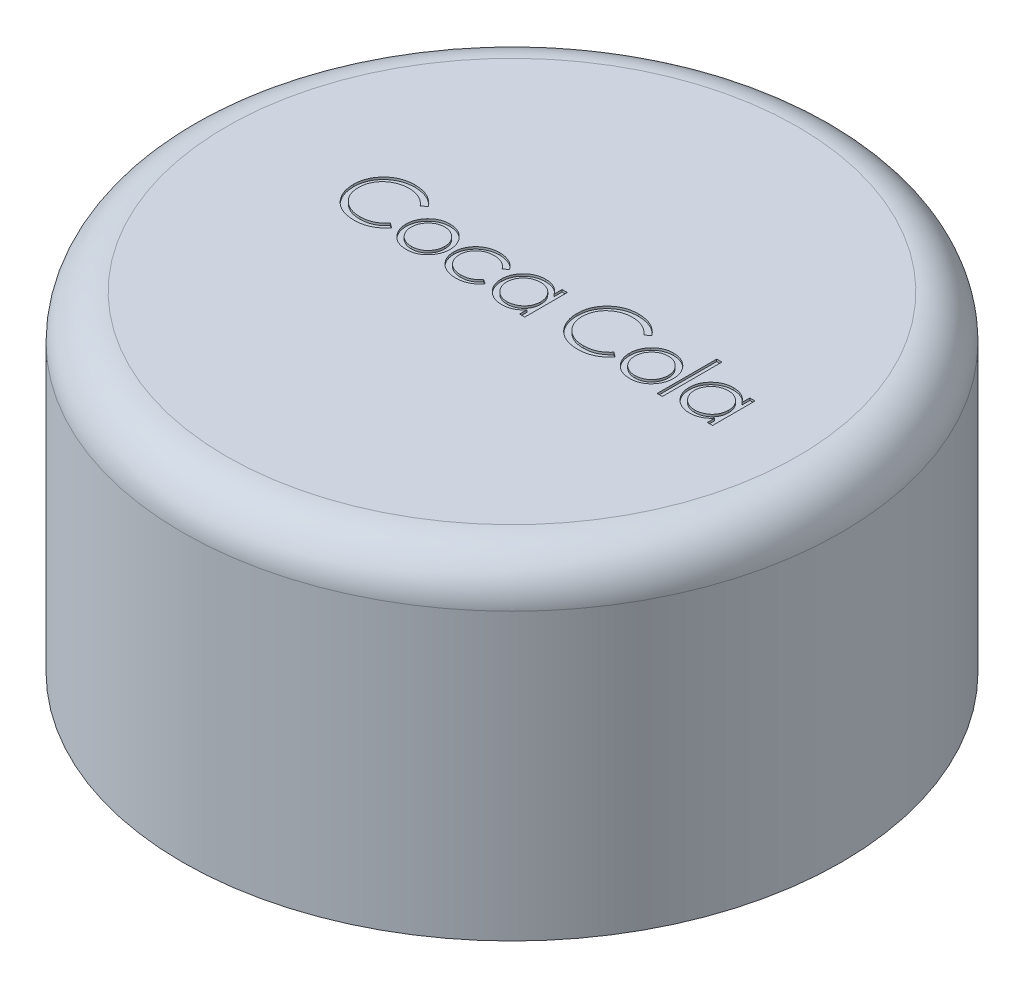
from build123d import *

# Parameters (mm, degrees)
CROQUIS1_R              = 15
CROQUIS1_R_2            = 13.85
SALIENTE_EXTRUIR1_DEPTH = 7.5
CROQUIS2_R              = 15
SALIENTE_EXTRUIR2_DEPTH = 2.15
REDONDEO1_R             = 2
CROQUIS3_W              = 0.237446581
CROQUIS3_H              = 2.713675213
CORTAR_EXTRUIR1_DEPTH   = 0.1


with BuildPart() as part:
    # Croquis1 → Saliente-Extruir1 (new body, symmetric)
    with BuildSketch(Plane(origin=(0, 0, 0), x_dir=(1, 0, 0), z_dir=(0, 1, 0))):
        Circle(CROQUIS1_R)
        Circle(CROQUIS1_R_2, mode=Mode.SUBTRACT)
    extrude(amount=SALIENTE_EXTRUIR1_DEPTH, both=True)

    # Croquis2 → Saliente-Extruir2 (add)
    with BuildSketch(Plane(origin=(0, 7.5, 0), x_dir=(1, 0, 0), z_dir=(0, 1, 0))):
        Circle(CROQUIS2_R)
    extrude(amount=-SALIENTE_EXTRUIR2_DEPTH)

    # Redondeo1
    redondeo1_edges = [part.edges().sort_by_distance(p)[0] for p in [
        (-15, 7.5, 0),
    ]]
    fillet(redondeo1_edges, radius=REDONDEO1_R)

    # Croquis3 → Cortar-Extruir1 (cut)
    with BuildSketch(Plane(origin=(0, 7.5, 0), x_dir=(1, 0, 0), z_dir=(0, 1, 0))):
        with BuildLine():
            Line((-5.255127494, 1.443894817), (-5.462893253, 1.28489041))
            add(Edge.make_bspline(
                [(-5.462893253, 1.28489041), (-5.477714371, 1.30255397), (-5.507156786, 1.337642948), (-5.554524159, 1.38691558), (-5.603889092, 1.43307801), (-5.655232713, 1.476350145), (-5.709479191, 1.515218772), (-5.765314437, 1.551709427), (-5.823672483, 1.584417776), (-5.904371711, 1.624077296), (-6.009938835, 1.665462782), (-6.142831362, 1.700163439), (-6.281557014, 1.722253256), (-6.376200437, 1.724645726), (-6.424339901, 1.725862632)],
                knots=[0, 0, 0, 0, 6.9158e-05, 0.000137384, 0.000204881, 0.000271861, 0.000338651, 0.000404954, 0.000471878, 0.000539197, 0.000674629, 0.00081116, 0.000950585, 0.001094913, 0.001094913, 0.001094913, 0.001094913], degree=3))
            add(Edge.make_bspline(
                [(-6.424339901, 1.725862632), (-6.450861205, 1.725557256), (-6.503657669, 1.724949337), (-6.58201098, 1.716929344), (-6.658901203, 1.705657179), (-6.734278323, 1.688931488), (-6.808046393, 1.66778552), (-6.880687673, 1.642517499), (-6.951150448, 1.611255209), (-7.020409473, 1.576701941), (-7.086766377, 1.537674051), (-7.149552038, 1.495103839), (-7.208537466, 1.449467677), (-7.263769322, 1.400594519), (-7.315304068, 1.348704466), (-7.362768285, 1.293244517), (-7.405997732, 1.234391981), (-7.445849293, 1.172922917), (-7.481539871, 1.109016372), (-7.511422578, 1.042435813), (-7.537884783, 0.974321402), (-7.558824092, 0.90390356), (-7.575397982, 0.831677778), (-7.586833775, 0.757450219), (-7.59476256, 0.681375949), (-7.595367456, 0.629812957), (-7.595672366, 0.603821533)],
                knots=[0, 0, 0, 0, 7.953e-05, 0.000158323, 0.000236054, 0.000312571, 0.000389743, 0.000466183, 0.000543086, 0.000620832, 0.000698279, 0.00077384, 0.000848263, 0.000921857, 0.000994939, 0.001067489, 0.001140633, 0.001213846, 0.001287153, 0.001359968, 0.001432611, 0.001506222, 0.001580153, 0.001654742, 0.001731424, 0.001809365, 0.001809365, 0.001809365, 0.001809365], degree=3))
            add(Edge.make_bspline(
                [(-7.595672366, 0.603821533), (-7.594718491, 0.564715119), (-7.592845684, 0.487934861), (-7.576178193, 0.375471364), (-7.55084994, 0.267732521), (-7.512889355, 0.165391807), (-7.466081501, 0.067187274), (-7.406935325, -0.025219478), (-7.338433537, -0.113224857), (-7.259607042, -0.19474899), (-7.173121693, -0.269220675), (-7.080330117, -0.334799984), (-6.981463423, -0.389466592), (-6.877613232, -0.434956742), (-6.767980396, -0.469924625), (-6.652762063, -0.494541552), (-6.532208829, -0.510599629), (-6.449833152, -0.512137), (-6.407909446, -0.512919419)],
                knots=[0, 0, 0, 0, 0.000117253, 0.000230211, 0.000340379, 0.000448694, 0.000557026, 0.000666132, 0.000777139, 0.000891093, 0.001005725, 0.001119096, 0.001231322, 0.001344067, 0.001458716, 0.001575878, 0.00169717, 0.001822874, 0.001822874, 0.001822874, 0.001822874], degree=3))
            add(Edge.make_bspline(
                [(-6.407909446, -0.512919419), (-6.361718722, -0.511642782), (-6.270804329, -0.509130055), (-6.1374785, -0.487843004), (-6.009846701, -0.453327792), (-5.887902067, -0.405024005), (-5.771988376, -0.342230603), (-5.661924234, -0.266107803), (-5.557616737, -0.175931504), (-5.494894399, -0.107076996), (-5.462893253, -0.071947197)],
                knots=[0, 0, 0, 0, 0.000138505, 0.000272612, 0.000403886, 0.000534492, 0.000665157, 0.000798504, 0.00093527, 0.001077735, 0.001077735, 0.001077735, 0.001077735], degree=3))
            Line((-5.462893253, -0.071947197), (-5.255127494, -0.22936156))
            add(Edge.make_bspline(
                [(-5.255127494, -0.22936156), (-5.271847732, -0.250935271), (-5.305208119, -0.293979355), (-5.359226977, -0.354660945), (-5.416133029, -0.411738401), (-5.476348953, -0.464751543), (-5.539182045, -0.514761169), (-5.60576052, -0.560346482), (-5.675209133, -0.602143757), (-5.747292579, -0.640415301), (-5.821934268, -0.674370601), (-5.899044764, -0.703439818), (-5.978291687, -0.728480658), (-6.05967866, -0.749081824), (-6.1433745, -0.765161751), (-6.22907718, -0.775911148), (-6.316971669, -0.783275571), (-6.376269648, -0.783946793), (-6.406319402, -0.784286941)],
                knots=[0, 0, 0, 0, 8.1865e-05, 0.000163337, 0.000243539, 0.000323515, 0.000403891, 0.000484308, 0.000565388, 0.000646949, 0.000729019, 0.000811214, 0.000894022, 0.000978221, 0.001062938, 0.001149519, 0.001237243, 0.00132737, 0.00132737, 0.00132737, 0.00132737], degree=3))
            add(Edge.make_bspline(
                [(-6.406319402, -0.784286941), (-6.434776221, -0.784088887), (-6.491046058, -0.78369726), (-6.574124281, -0.777353181), (-6.65500331, -0.768697725), (-6.733451985, -0.755665007), (-6.809898407, -0.740285654), (-6.883649563, -0.719669883), (-6.95543118, -0.696576168), (-7.024954866, -0.669433708), (-7.092279759, -0.638805403), (-7.157188711, -0.604189165), (-7.219651871, -0.565876089), (-7.28028335, -0.524710694), (-7.338187476, -0.47937071), (-7.393866034, -0.430485813), (-7.447631239, -0.37822077), (-7.480895174, -0.340532874), (-7.497619649, -0.321584116)],
                knots=[0, 0, 0, 0, 8.5347e-05, 0.000168763, 0.000249828, 0.000329295, 0.000407256, 0.000483631, 0.000558888, 0.000633396, 0.000707395, 0.000780662, 0.000853927, 0.000927138, 0.001000399, 0.00107439, 0.001149349, 0.001225147, 0.001225147, 0.001225147, 0.001225147], degree=3))
            add(Edge.make_bspline(
                [(-7.497619649, -0.321584116), (-7.524407308, -0.288669051), (-7.577659222, -0.223236299), (-7.645789947, -0.117186778), (-7.704109825, -0.006463787), (-7.751263051, 0.109514374), (-7.788125355, 0.230487458), (-7.81366233, 0.356516448), (-7.830256697, 0.487483643), (-7.832154356, 0.576562644), (-7.833118947, 0.621842032)],
                knots=[0, 0, 0, 0, 0.000127231, 0.000252926, 0.000377389, 0.000502191, 0.000627939, 0.00075621, 0.000887559, 0.001023346, 0.001023346, 0.001023346, 0.001023346], degree=3))
            add(Edge.make_bspline(
                [(-7.833118947, 0.621842032), (-7.831943295, 0.669433357), (-7.829630273, 0.763066318), (-7.809978689, 0.900478771), (-7.778365671, 1.032128936), (-7.733464451, 1.157771052), (-7.676537192, 1.278065966), (-7.606213502, 1.392094734), (-7.523310364, 1.500586601), (-7.428477977, 1.601895371), (-7.324483622, 1.694529286), (-7.213117614, 1.776025643), (-7.094597928, 1.843847813), (-6.970230266, 1.90054134), (-6.839083352, 1.944117809), (-6.701436996, 1.974622897), (-6.55754984, 1.993610241), (-6.45938003, 1.996010547), (-6.40949949, 1.997230153)],
                knots=[0, 0, 0, 0, 0.000142716, 0.000280784, 0.000415505, 0.000548276, 0.000680327, 0.000814043, 0.000949414, 0.00108929, 0.001229699, 0.00136667, 0.00150249, 0.001638645, 0.001776082, 0.001916238, 0.002061065, 0.002210665, 0.002210665, 0.002210665, 0.002210665], degree=3))
            add(Edge.make_bspline(
                [(-6.40949949, 1.997230153), (-6.379099264, 1.99686568), (-6.318925078, 1.996144241), (-6.22990968, 1.989109241), (-6.14324554, 1.977381693), (-6.058872953, 1.96141895), (-5.976381451, 1.941607463), (-5.896401507, 1.915799023), (-5.818463809, 1.886289265), (-5.743059897, 1.852302805), (-5.670551552, 1.814152352), (-5.600961359, 1.772260779), (-5.534842091, 1.726680022), (-5.471728497, 1.67779774), (-5.412676361, 1.624579782), (-5.356009053, 1.568489932), (-5.303650976, 1.507912577), (-5.271331597, 1.465273133), (-5.255127494, 1.443894817)],
                knots=[0, 0, 0, 0, 9.1187e-05, 0.000180496, 0.000267672, 0.000353431, 0.000438016, 0.000521994, 0.000605369, 0.000687922, 0.000769951, 0.000851031, 0.000931448, 0.001010752, 0.001090332, 0.001169785, 0.00124981, 0.001330276, 0.001330276, 0.001330276, 0.001330276], degree=3))
        make_face()
        with BuildLine():
            add(Edge.make_bspline(
                [(-4.070226653, 1.25096947), (-4.033947536, 1.250196969), (-3.962813054, 1.248682283), (-3.858636855, 1.232493589), (-3.759194996, 1.207738141), (-3.664106624, 1.173514995), (-3.574589544, 1.12764233), (-3.489339853, 1.072904354), (-3.408591281, 1.008056799), (-3.36019292, 0.957893259), (-3.335626293, 0.932430641)],
                knots=[0, 0, 0, 0, 0.000108758, 0.000213247, 0.000315443, 0.000415879, 0.000515669, 0.000616524, 0.000719414, 0.000825476, 0.000825476, 0.000825476, 0.000825476], degree=3))
            add(Edge.make_bspline(
                [(-3.335626293, 0.932430641), (-3.314473268, 0.908078402), (-3.272576587, 0.859845206), (-3.218854288, 0.781637689), (-3.172573704, 0.700644875), (-3.135484442, 0.615791241), (-3.106240406, 0.527817531), (-3.085477648, 0.436421368), (-3.073127703, 0.341804594), (-3.071462365, 0.27754574), (-3.070618947, 0.245001588)],
                knots=[0, 0, 0, 0, 9.6703e-05, 0.000191534, 0.000284097, 0.000376175, 0.000468861, 0.00056182, 0.000656947, 0.000754562, 0.000754562, 0.000754562, 0.000754562], degree=3))
            add(Edge.make_bspline(
                [(-3.070618947, 0.245001588), (-3.071360792, 0.212268806), (-3.072826711, 0.147587303), (-3.086693611, 0.052322663), (-3.108261753, -0.040050804), (-3.139128679, -0.129146364), (-3.178708916, -0.215236359), (-3.227007233, -0.297944768), (-3.284362563, -0.377434773), (-3.349377489, -0.453031401), (-3.421232181, -0.522704671), (-3.499183079, -0.583429017), (-3.581698331, -0.635454812), (-3.669875151, -0.677362103), (-3.762908311, -0.710404555), (-3.860998476, -0.733612305), (-3.963993261, -0.747644054), (-4.034317411, -0.749445922), (-4.070226653, -0.750366)],
                knots=[0, 0, 0, 0, 9.8144e-05, 0.000193938, 0.00028817, 0.00038237, 0.000476284, 0.000572006, 0.000669231, 0.000769951, 0.000870783, 0.00096896, 0.001065874, 0.001162833, 0.001261235, 0.001361507, 0.001464724, 0.001572422, 0.001572422, 0.001572422, 0.001572422], degree=3))
            add(Edge.make_bspline(
                [(-4.070226653, -0.750366), (-4.106311828, -0.749442834), (-4.176986466, -0.747634767), (-4.280344798, -0.733666821), (-4.37861076, -0.710415251), (-4.471765712, -0.677253515), (-4.560321638, -0.635453473), (-4.643315002, -0.583586303), (-4.721329224, -0.522686662), (-4.793199117, -0.453036281), (-4.858209967, -0.377433516), (-4.915566348, -0.297945094), (-4.963864392, -0.215236274), (-5.003444701, -0.129146387), (-5.034311608, -0.040050798), (-5.055879755, 0.052322662), (-5.069746654, 0.147587303), (-5.071212573, 0.212268806), (-5.071954418, 0.245001588)],
                knots=[0, 0, 0, 0, 0.000108228, 0.00021197, 0.000312243, 0.000410644, 0.000508082, 0.000605445, 0.000703622, 0.000804454, 0.000905174, 0.001002399, 0.001098121, 0.001192035, 0.001286235, 0.001380467, 0.001476261, 0.001574405, 0.001574405, 0.001574405, 0.001574405], degree=3))
            add(Edge.make_bspline(
                [(-5.071954418, 0.245001588), (-5.071105248, 0.277368858), (-5.069424039, 0.341450489), (-5.057086512, 0.435889398), (-5.036404746, 0.527130877), (-5.007125654, 0.614765016), (-4.969694528, 0.699246804), (-4.924064269, 0.780439742), (-4.869793969, 0.858293615), (-4.828063922, 0.906464473), (-4.806947072, 0.930840597)],
                knots=[0, 0, 0, 0, 9.7085e-05, 0.000192212, 0.000285172, 0.000377355, 0.000468948, 0.000561973, 0.000656369, 0.000753072, 0.000753072, 0.000753072, 0.000753072], degree=3))
            add(Edge.make_bspline(
                [(-4.806947072, 0.930840597), (-4.782417483, 0.956524033), (-4.734175729, 1.00703503), (-4.653025202, 1.071693545), (-4.56798523, 1.127570577), (-4.477478887, 1.172531764), (-4.382468632, 1.207939453), (-4.28251718, 1.232557431), (-4.177987475, 1.248623956), (-4.106504905, 1.25017984), (-4.070226653, 1.25096947)],
                knots=[0, 0, 0, 0, 0.000106437, 0.000209326, 0.000310469, 0.000411207, 0.000511826, 0.000614021, 0.000719559, 0.000828317, 0.000828317, 0.000828317, 0.000828317], degree=3))
        make_face()
        with BuildLine():
            add(Edge.make_bspline(
                [(-4.071286683, 1.013522889), (-4.096941901, 1.012793703), (-4.147590051, 1.011354156), (-4.222141761, 1.000405014), (-4.293911997, 0.983057794), (-4.363036921, 0.95841068), (-4.429283426, 0.926585917), (-4.492714938, 0.887496859), (-4.553518033, 0.841661231), (-4.610503283, 0.789150759), (-4.662801817, 0.731789852), (-4.708520287, 0.670672343), (-4.747395219, 0.606789569), (-4.779780339, 0.5400751), (-4.803900654, 0.469852859), (-4.821418355, 0.396918096), (-4.832357168, 0.321122215), (-4.83378318, 0.269595731), (-4.834507836, 0.243411544)],
                knots=[0, 0, 0, 0, 7.6942e-05, 0.000151897, 0.000225556, 0.000298145, 0.000371633, 0.000445627, 0.000521313, 0.000599714, 0.000677758, 0.000753868, 0.000828314, 0.000901803, 0.000975891, 0.00105058, 0.001126585, 0.001205115, 0.001205115, 0.001205115, 0.001205115], degree=3))
            add(Edge.make_bspline(
                [(-4.834507836, 0.243411544), (-4.833293154, 0.209581142), (-4.830882237, 0.142434121), (-4.811276434, 0.043547142), (-4.778478472, -0.051386758), (-4.734189278, -0.14181105), (-4.678697673, -0.225474022), (-4.613317569, -0.300064966), (-4.538750652, -0.364461383), (-4.455885798, -0.417892736), (-4.36641557, -0.460346837), (-4.271727755, -0.490432968), (-4.172969612, -0.509990735), (-4.10547763, -0.511934647), (-4.071286683, -0.512919419)],
                knots=[0, 0, 0, 0, 0.000101432, 0.000201324, 0.000301053, 0.00040203, 0.000502578, 0.00060135, 0.000698678, 0.000797177, 0.000896278, 0.000994835, 0.001094627, 0.001197086, 0.001197086, 0.001197086, 0.001197086], degree=3))
            add(Edge.make_bspline(
                [(-4.071286683, -0.512919419), (-4.037097701, -0.51192891), (-3.969609602, -0.509973671), (-3.870988677, -0.490531468), (-3.776559662, -0.460215011), (-3.687182363, -0.417940483), (-3.604355228, -0.364258479), (-3.529252024, -0.300428599), (-3.464430157, -0.225276461), (-3.408993444, -0.141700234), (-3.363978942, -0.051526944), (-3.331334498, 0.043564663), (-3.311681561, 0.142429659), (-3.309277006, 0.209579647), (-3.308065529, 0.243411544)],
                knots=[0, 0, 0, 0, 0.000102459, 0.000202251, 0.000300304, 0.000399405, 0.000497904, 0.000595634, 0.000694057, 0.000794604, 0.000895816, 0.000995545, 0.001095437, 0.001196869, 0.001196869, 0.001196869, 0.001196869], degree=3))
            add(Edge.make_bspline(
                [(-3.308065529, 0.243411544), (-3.308789935, 0.269595888), (-3.310215457, 0.32112268), (-3.32115784, 0.39691632), (-3.338662326, 0.469859373), (-3.362831346, 0.540051066), (-3.395075749, 0.606962304), (-3.434700349, 0.670484776), (-3.480232136, 0.73200157), (-3.533161745, 0.788965334), (-3.590087513, 0.841681701), (-3.65091525, 0.887514632), (-3.714252704, 0.926414124), (-3.780306752, 0.958682889), (-3.849440538, 0.982833557), (-3.921110213, 1.000505178), (-3.995343837, 1.011307886), (-4.045810495, 1.012779832), (-4.071286683, 1.013522889)],
                knots=[0, 0, 0, 0, 7.853e-05, 0.000154535, 0.000229224, 0.000303312, 0.000376801, 0.000451523, 0.000527634, 0.000606035, 0.000684436, 0.000760122, 0.000834116, 0.000907127, 0.000980215, 0.001053359, 0.001128314, 0.001204727, 0.001204727, 0.001204727, 0.001204727], degree=3))
        make_face(mode=Mode.SUBTRACT)
        with BuildLine():
            Line((-0.920031341, 0.79780691), (-1.118786849, 0.674313487))
            add(Edge.make_bspline(
                [(-1.118786849, 0.674313487), (-1.140580855, 0.701398046), (-1.183478654, 0.754709404), (-1.257969625, 0.823508579), (-1.337353253, 0.882599141), (-1.422986063, 0.930756143), (-1.514747948, 0.967965216), (-1.612277032, 0.994295192), (-1.715559407, 1.010702566), (-1.786365838, 1.012567378), (-1.822646358, 1.013522889)],
                knots=[0, 0, 0, 0, 0.00010417, 0.000205042, 0.000303203, 0.000400501, 0.000498924, 0.000599472, 0.000702993, 0.000811776, 0.000811776, 0.000811776, 0.000811776], degree=3))
            add(Edge.make_bspline(
                [(-1.822646358, 1.013522889), (-1.851643903, 1.012723966), (-1.908753779, 1.01115051), (-1.99259355, 1.001315197), (-2.072454138, 0.983442964), (-2.148836102, 0.959894324), (-2.221196181, 0.928333093), (-2.289723958, 0.889923337), (-2.355027275, 0.845284319), (-2.41521374, 0.793569204), (-2.470269002, 0.737327354), (-2.517968776, 0.677037358), (-2.559498481, 0.614505059), (-2.592084532, 0.548168921), (-2.618750881, 0.479546547), (-2.636294056, 0.407342621), (-2.64798463, 0.332482163), (-2.649322158, 0.281441513), (-2.649999289, 0.255601882)],
                knots=[0, 0, 0, 0, 8.7002e-05, 0.000171347, 0.000252751, 0.000332207, 0.00041078, 0.00048908, 0.000567587, 0.000647668, 0.000726754, 0.000803321, 0.000878, 0.000951479, 0.001024617, 0.001098404, 0.00117396, 0.001251431, 0.001251431, 0.001251431, 0.001251431], degree=3))
            add(Edge.make_bspline(
                [(-2.649999289, 0.255601882), (-2.648654259, 0.22175849), (-2.645982323, 0.154527717), (-2.625041338, 0.055287723), (-2.590763126, -0.040660543), (-2.543850346, -0.132635861), (-2.484525369, -0.21775168), (-2.4148473, -0.294090363), (-2.334777517, -0.360172718), (-2.245021529, -0.414958496), (-2.147686806, -0.459001315), (-2.043826429, -0.490378882), (-1.934289095, -0.509317283), (-1.859293519, -0.511703026), (-1.821056314, -0.512919419)],
                knots=[0, 0, 0, 0, 0.000101467, 0.000201567, 0.00030282, 0.000406407, 0.000510356, 0.000613143, 0.000715547, 0.000820721, 0.000927707, 0.00103518, 0.001145405, 0.001260065, 0.001260065, 0.001260065, 0.001260065], degree=3))
            add(Edge.make_bspline(
                [(-1.821056314, -0.512919419), (-1.786014002, -0.511937061), (-1.71714656, -0.510006467), (-1.616478434, -0.493731596), (-1.520638858, -0.467089087), (-1.42963124, -0.429935804), (-1.343621876, -0.381912027), (-1.263166488, -0.322676225), (-1.186664154, -0.253932486), (-1.141687273, -0.200775448), (-1.118786849, -0.173710017)],
                knots=[0, 0, 0, 0, 0.000105077, 0.000206504, 0.000305008, 0.00040294, 0.0005007, 0.000599717, 0.000702147, 0.0008084, 0.0008084, 0.0008084, 0.0008084], degree=3))
            Line((-1.118786849, -0.173710017), (-0.920031341, -0.304093631))
            add(Edge.make_bspline(
                [(-0.920031341, -0.304093631), (-0.931814901, -0.321397931), (-0.955342911, -0.355949095), (-0.994673319, -0.404665778), (-1.037097239, -0.450266097), (-1.082449163, -0.492688928), (-1.130136915, -0.532949455), (-1.181789561, -0.569122966), (-1.235741589, -0.603242743), (-1.292626369, -0.63394414), (-1.351855765, -0.661541181), (-1.413346436, -0.685271411), (-1.476831175, -0.705659527), (-1.542384626, -0.72186514), (-1.610136026, -0.734800119), (-1.679910154, -0.743382977), (-1.751682981, -0.749789886), (-1.800194071, -0.750172297), (-1.824766417, -0.750366)],
                knots=[0, 0, 0, 0, 6.2786e-05, 0.000125364, 0.000187617, 0.000249484, 0.000311577, 0.000374669, 0.000438491, 0.000502998, 0.000568446, 0.000634392, 0.000700601, 0.000768346, 0.000836849, 0.000907389, 0.000979178, 0.001052867, 0.001052867, 0.001052867, 0.001052867], degree=3))
            add(Edge.make_bspline(
                [(-1.824766417, -0.750366), (-1.862269882, -0.749692235), (-1.935776947, -0.748371651), (-2.043365986, -0.733850958), (-2.146185841, -0.711960379), (-2.244201386, -0.680540176), (-2.337427878, -0.640093113), (-2.42577839, -0.590686398), (-2.50896038, -0.531909747), (-2.58615127, -0.464809321), (-2.657045577, -0.392055979), (-2.717919542, -0.313550386), (-2.770719241, -0.23217888), (-2.813118753, -0.146144298), (-2.846869703, -0.056590117), (-2.869929904, 0.037201076), (-2.884844646, 0.134456054), (-2.886570772, 0.200777935), (-2.887445871, 0.234401294)],
                knots=[0, 0, 0, 0, 0.000112443, 0.000220389, 0.000325076, 0.00042749, 0.000528612, 0.000629461, 0.000730631, 0.000833593, 0.000935924, 0.001034846, 0.001131147, 0.001226433, 0.001322027, 0.001417666, 0.001515709, 0.001616524, 0.001616524, 0.001616524, 0.001616524], degree=3))
            add(Edge.make_bspline(
                [(-2.887445871, 0.234401294), (-2.887112483, 0.257214753), (-2.886449321, 0.30259449), (-2.878842983, 0.369946117), (-2.869016756, 0.436400792), (-2.852366348, 0.501116151), (-2.833134442, 0.565073721), (-2.808584486, 0.627502613), (-2.779786182, 0.688692932), (-2.747089769, 0.748487049), (-2.710283397, 0.805901284), (-2.66955175, 0.860143637), (-2.626428948, 0.911865722), (-2.578897602, 0.959281898), (-2.528974768, 1.004288424), (-2.475248041, 1.045682958), (-2.418025582, 1.08358716), (-2.358166761, 1.118701916), (-2.295706413, 1.149967679), (-2.231022085, 1.17690471), (-2.164503545, 1.199925407), (-2.096044389, 1.218150602), (-2.026099008, 1.233434011), (-1.954116211, 1.243048098), (-1.880371376, 1.249841292), (-1.830436168, 1.250590284), (-1.805155873, 1.25096947)],
                knots=[0, 0, 0, 0, 6.8405e-05, 0.000136068, 0.000203163, 0.000269751, 0.000336307, 0.000403433, 0.00047077, 0.000539084, 0.000607743, 0.000675162, 0.000742482, 0.000809568, 0.000876383, 0.00094402, 0.001012816, 0.001082175, 0.001152099, 0.001222183, 0.001292245, 0.001363089, 0.001434608, 0.001506865, 0.001580811, 0.001656633, 0.001656633, 0.001656633, 0.001656633], degree=3))
            add(Edge.make_bspline(
                [(-1.805155873, 1.25096947), (-1.773496506, 1.250272564), (-1.710336019, 1.248882236), (-1.616642747, 1.237181112), (-1.524329476, 1.219539892), (-1.435015891, 1.193404479), (-1.349784895, 1.161757549), (-1.27000512, 1.126218176), (-1.197554566, 1.084947255), (-1.131085495, 1.039801693), (-1.070473598, 0.988880056), (-1.01509669, 0.931573606), (-0.963819194, 0.868180589), (-0.934747751, 0.821458399), (-0.920031341, 0.79780691)],
                knots=[0, 0, 0, 0, 9.4945e-05, 0.000189416, 0.000282862, 0.000376633, 0.000468195, 0.000555485, 0.000638319, 0.000717999, 0.000796244, 0.00087533, 0.00095678, 0.00104028, 0.00104028, 0.00104028, 0.00104028], degree=3))
        make_face()
        with BuildLine():
            Line((1.298398147, 1.21704853), (1.298398147, -0.71644506))
            Line((1.298398147, -0.71644506), (1.060951565, -0.71644506))
            Line((1.060951565, -0.71644506), (1.060951565, -0.382005791))
            add(Edge.make_bspline(
                [(1.060951565, -0.382005791), (1.034176646, -0.412273817), (0.981925055, -0.471342251), (0.894657067, -0.548511513), (0.802152552, -0.612297506), (0.704860481, -0.663815597), (0.602868714, -0.702514354), (0.496403339, -0.730020557), (0.385420926, -0.747705183), (0.309634919, -0.749471104), (0.271229677, -0.750366)],
                knots=[0, 0, 0, 0, 0.000121151, 0.000236428, 0.000348455, 0.000457515, 0.000565889, 0.000674904, 0.000786968, 0.000902103, 0.000902103, 0.000902103, 0.000902103], degree=3))
            add(Edge.make_bspline(
                [(0.271229677, -0.750366), (0.237084855, -0.749438921), (0.169749753, -0.74761068), (0.070698011, -0.733427272), (-0.024621726, -0.710649957), (-0.116299528, -0.67897488), (-0.203742161, -0.636958426), (-0.287698306, -0.586656411), (-0.367733019, -0.526754116), (-0.442626385, -0.458273881), (-0.511593433, -0.383891956), (-0.572115943, -0.30455812), (-0.622578092, -0.220615426), (-0.664775415, -0.133126673), (-0.697278604, -0.04141837), (-0.719937244, 0.054192346), (-0.73410413, 0.153592429), (-0.735931615, 0.221280044), (-0.736858264, 0.255601882)],
                knots=[0, 0, 0, 0, 0.000102404, 0.000201945, 0.000299517, 0.000396067, 0.00049232, 0.000590034, 0.000689253, 0.000791683, 0.00089408, 0.000993194, 0.001090454, 0.001187414, 0.00128414, 0.001381711, 0.001481777, 0.001584711, 0.001584711, 0.001584711, 0.001584711], degree=3))
            add(Edge.make_bspline(
                [(-0.736858264, 0.255601882), (-0.735911077, 0.289214324), (-0.73403854, 0.35566431), (-0.720088785, 0.453392849), (-0.69663082, 0.547522725), (-0.663710721, 0.63775089), (-0.621496862, 0.724186524), (-0.570146463, 0.806890757), (-0.509655815, 0.886091432), (-0.439917388, 0.959926229), (-0.364371461, 1.028128717), (-0.283553551, 1.087402222), (-0.199474047, 1.138592935), (-0.110828795, 1.179152408), (-0.018929852, 1.211967624), (0.077040907, 1.234671117), (0.176684184, 1.24804945), (0.244334735, 1.249986777), (0.278649883, 1.25096947)],
                knots=[0, 0, 0, 0, 0.000100816, 0.000199307, 0.000295461, 0.000391368, 0.000486896, 0.000583529, 0.000682964, 0.000785334, 0.000887803, 0.000987873, 0.001085587, 0.001182574, 0.001279799, 0.001377887, 0.001477881, 0.001580814, 0.001580814, 0.001580814, 0.001580814], degree=3))
            add(Edge.make_bspline(
                [(0.278649883, 1.25096947), (0.31811049, 1.249882598), (0.39549088, 1.247751294), (0.508678125, 1.230014589), (0.615754605, 1.200049796), (0.717546883, 1.159290735), (0.813689426, 1.105127707), (0.903272039, 1.036804761), (0.987232255, 0.954752792), (1.03590069, 0.891728706), (1.060951565, 0.859288614)],
                knots=[0, 0, 0, 0, 0.000118337, 0.000232053, 0.000342644, 0.000451302, 0.000560235, 0.000672599, 0.000788411, 0.000911251, 0.000911251, 0.000911251, 0.000911251], degree=3))
            Line((1.060951565, 0.859288614), (1.060951565, 1.21704853))
            Line((1.060951565, 1.21704853), (1.298398147, 1.21704853))
        make_face()
        with BuildLine():
            add(Edge.make_bspline(
                [(0.281829971, 1.013522889), (0.247120918, 1.012287936), (0.178610768, 1.009850337), (0.078035838, 0.990820373), (-0.018207041, 0.959157614), (-0.109636514, 0.915855225), (-0.19480832, 0.86140493), (-0.27092794, 0.795545313), (-0.338617959, 0.720073284), (-0.39554742, 0.635329427), (-0.441955713, 0.544480513), (-0.474587933, 0.44951442), (-0.496109329, 0.35214399), (-0.498308032, 0.28610196), (-0.499411683, 0.252951808)],
                knots=[0, 0, 0, 0, 0.000104077, 0.000205432, 0.000305829, 0.0004073, 0.000508155, 0.000608127, 0.00070835, 0.0008114, 0.000913561, 0.001013462, 0.001112005, 0.001211322, 0.001211322, 0.001211322, 0.001211322], degree=3))
            add(Edge.make_bspline(
                [(-0.499411683, 0.252951808), (-0.498001912, 0.219999763), (-0.495187897, 0.154224833), (-0.474965646, 0.056721659), (-0.441038598, -0.038266813), (-0.394742515, -0.12993435), (-0.336771079, -0.215042569), (-0.26957549, -0.291953257), (-0.192505932, -0.358091219), (-0.107138114, -0.413455337), (-0.015964232, -0.458179386), (0.07991618, -0.489298649), (0.17870074, -0.509390186), (0.245868874, -0.511737022), (0.279709912, -0.512919419)],
                knots=[0, 0, 0, 0, 9.8823e-05, 0.000197259, 0.000297336, 0.000400683, 0.000504468, 0.000605484, 0.000706204, 0.00080808, 0.000910009, 0.001009903, 0.001109795, 0.001211227, 0.001211227, 0.001211227, 0.001211227], degree=3))
            add(Edge.make_bspline(
                [(0.279709912, -0.512919419), (0.314065304, -0.511664566), (0.382394771, -0.509168786), (0.48326808, -0.490057353), (0.581160106, -0.458482131), (0.674737356, -0.414713148), (0.76191086, -0.360468004), (0.840150327, -0.296962644), (0.906308231, -0.223103689), (0.962394311, -0.141932204), (1.006372156, -0.05294754), (1.038406439, 0.04179914), (1.057345998, 0.142311135), (1.059733092, 0.210999936), (1.060951565, 0.246061617)],
                knots=[0, 0, 0, 0, 0.000103019, 0.000204895, 0.000306804, 0.000410899, 0.000513992, 0.000614158, 0.000712096, 0.000810448, 0.000909289, 0.001008848, 0.001109681, 0.001214817, 0.001214817, 0.001214817, 0.001214817], degree=3))
            add(Edge.make_bspline(
                [(1.060951565, 0.246061617), (1.060226111, 0.272775334), (1.058798187, 0.325356383), (1.047889363, 0.402559923), (1.030536532, 0.476441966), (1.006084368, 0.547080189), (0.97396298, 0.61408404), (0.93522211, 0.677934621), (0.88918049, 0.738299846), (0.836579285, 0.794348477), (0.779002019, 0.845470863), (0.718076384, 0.891103354), (0.653080545, 0.928590105), (0.585107547, 0.959615352), (0.514039455, 0.984304114), (0.439297975, 1.000774573), (0.36167755, 1.012083863), (0.308726068, 1.013038163), (0.281829971, 1.013522889)],
                knots=[0, 0, 0, 0, 8.0118e-05, 0.000157698, 0.000233418, 0.000307506, 0.000381473, 0.000455919, 0.000531183, 0.000608806, 0.000686141, 0.000761935, 0.00083675, 0.000910749, 0.000985839, 0.001061955, 0.00114006, 0.001220685, 0.001220685, 0.001220685, 0.001220685], degree=3))
        make_face(mode=Mode.SUBTRACT)
        with BuildLine():
            Line((4.921154557, 1.443894817), (4.713388798, 1.28489041))
            add(Edge.make_bspline(
                [(4.713388798, 1.28489041), (4.69856768, 1.30255397), (4.669125265, 1.337642948), (4.621757892, 1.38691558), (4.572392959, 1.43307801), (4.521049338, 1.476350145), (4.466802861, 1.515218772), (4.410967614, 1.551709427), (4.352609568, 1.584417776), (4.27191034, 1.624077296), (4.166343217, 1.665462782), (4.03345069, 1.700163439), (3.894725038, 1.722253256), (3.800081614, 1.724645726), (3.75194215, 1.725862632)],
                knots=[0, 0, 0, 0, 6.9158e-05, 0.000137384, 0.000204881, 0.000271861, 0.000338651, 0.000404954, 0.000471878, 0.000539197, 0.000674629, 0.00081116, 0.000950585, 0.001094913, 0.001094913, 0.001094913, 0.001094913], degree=3))
            add(Edge.make_bspline(
                [(3.75194215, 1.725862632), (3.725420847, 1.725557256), (3.672624382, 1.724949337), (3.594271072, 1.716929344), (3.517380848, 1.705657179), (3.442003728, 1.688931488), (3.368235658, 1.66778552), (3.295594378, 1.642517499), (3.225131603, 1.611255209), (3.155872578, 1.576701941), (3.089515675, 1.537674051), (3.026730013, 1.495103839), (2.967744585, 1.449467677), (2.91251273, 1.400594519), (2.860977983, 1.348704466), (2.813513766, 1.293244517), (2.770284319, 1.234391981), (2.730432758, 1.172922917), (2.69474218, 1.109016372), (2.664859474, 1.042435813), (2.638397268, 0.974321402), (2.61745796, 0.90390356), (2.600884069, 0.831677778), (2.589448276, 0.757450219), (2.581519491, 0.681375949), (2.580914596, 0.629812957), (2.580609685, 0.603821533)],
                knots=[0, 0, 0, 0, 7.953e-05, 0.000158323, 0.000236054, 0.000312571, 0.000389743, 0.000466183, 0.000543086, 0.000620832, 0.000698279, 0.00077384, 0.000848263, 0.000921857, 0.000994939, 0.001067489, 0.001140633, 0.001213846, 0.001287153, 0.001359968, 0.001432611, 0.001506222, 0.001580153, 0.001654742, 0.001731424, 0.001809365, 0.001809365, 0.001809365, 0.001809365], degree=3))
            add(Edge.make_bspline(
                [(2.580609685, 0.603821533), (2.58156356, 0.564715119), (2.583436367, 0.487934861), (2.600103858, 0.375471364), (2.625432112, 0.267732521), (2.663392696, 0.165391807), (2.71020055, 0.067187274), (2.769346727, -0.025219478), (2.837848514, -0.113224857), (2.91667501, -0.19474899), (3.003160359, -0.269220675), (3.095951935, -0.334799984), (3.194818628, -0.389466592), (3.298668819, -0.434956742), (3.408301655, -0.469924625), (3.523519988, -0.494541552), (3.644073222, -0.510599629), (3.7264489, -0.512137), (3.768372606, -0.512919419)],
                knots=[0, 0, 0, 0, 0.000117253, 0.000230211, 0.000340379, 0.000448694, 0.000557026, 0.000666132, 0.000777139, 0.000891093, 0.001005725, 0.001119096, 0.001231322, 0.001344067, 0.001458716, 0.001575878, 0.00169717, 0.001822874, 0.001822874, 0.001822874, 0.001822874], degree=3))
            add(Edge.make_bspline(
                [(3.768372606, -0.512919419), (3.814563329, -0.511642782), (3.905477722, -0.509130055), (4.038803551, -0.487843004), (4.16643535, -0.453327792), (4.288379984, -0.405024005), (4.404293675, -0.342230603), (4.514357817, -0.266107803), (4.618665314, -0.175931504), (4.681387652, -0.107076996), (4.713388798, -0.071947197)],
                knots=[0, 0, 0, 0, 0.000138505, 0.000272612, 0.000403886, 0.000534492, 0.000665157, 0.000798504, 0.00093527, 0.001077735, 0.001077735, 0.001077735, 0.001077735], degree=3))
            Line((4.713388798, -0.071947197), (4.921154557, -0.22936156))
            add(Edge.make_bspline(
                [(4.921154557, -0.22936156), (4.904434319, -0.250935271), (4.871073932, -0.293979355), (4.817055074, -0.354660945), (4.760149022, -0.411738401), (4.699933098, -0.464751543), (4.637100006, -0.514761169), (4.570521532, -0.560346482), (4.501072918, -0.602143757), (4.428989473, -0.640415301), (4.354347783, -0.674370601), (4.277237288, -0.703439818), (4.197990364, -0.728480658), (4.116603391, -0.749081824), (4.032907551, -0.765161751), (3.947204871, -0.775911148), (3.859310382, -0.783275571), (3.800012403, -0.783946793), (3.76996265, -0.784286941)],
                knots=[0, 0, 0, 0, 8.1865e-05, 0.000163337, 0.000243539, 0.000323515, 0.000403891, 0.000484308, 0.000565388, 0.000646949, 0.000729019, 0.000811214, 0.000894022, 0.000978221, 0.001062938, 0.001149519, 0.001237243, 0.00132737, 0.00132737, 0.00132737, 0.00132737], degree=3))
            add(Edge.make_bspline(
                [(3.76996265, -0.784286941), (3.74150583, -0.784088887), (3.685235993, -0.78369726), (3.60215777, -0.777353181), (3.521278742, -0.768697725), (3.442830066, -0.755665007), (3.366383644, -0.740285654), (3.292632488, -0.719669883), (3.220850871, -0.696576168), (3.151327185, -0.669433708), (3.084002293, -0.638805403), (3.01909334, -0.604189165), (2.95663018, -0.565876089), (2.895998701, -0.524710694), (2.838094575, -0.47937071), (2.782416017, -0.430485813), (2.728650812, -0.37822077), (2.695386878, -0.340532874), (2.678662403, -0.321584116)],
                knots=[0, 0, 0, 0, 8.5347e-05, 0.000168763, 0.000249828, 0.000329295, 0.000407256, 0.000483631, 0.000558888, 0.000633396, 0.000707395, 0.000780662, 0.000853927, 0.000927138, 0.001000399, 0.00107439, 0.001149349, 0.001225147, 0.001225147, 0.001225147, 0.001225147], degree=3))
            add(Edge.make_bspline(
                [(2.678662403, -0.321584116), (2.651874744, -0.288669051), (2.59862283, -0.223236299), (2.530492105, -0.117186778), (2.472172226, -0.006463787), (2.425019001, 0.109514374), (2.388156696, 0.230487458), (2.362619722, 0.356516448), (2.346025354, 0.487483643), (2.344127695, 0.576562644), (2.343163104, 0.621842032)],
                knots=[0, 0, 0, 0, 0.000127231, 0.000252926, 0.000377389, 0.000502191, 0.000627939, 0.00075621, 0.000887559, 0.001023346, 0.001023346, 0.001023346, 0.001023346], degree=3))
            add(Edge.make_bspline(
                [(2.343163104, 0.621842032), (2.344338756, 0.669433357), (2.346651779, 0.763066318), (2.366303362, 0.900478771), (2.397916381, 1.032128936), (2.4428176, 1.157771052), (2.49974486, 1.278065966), (2.57006855, 1.392094734), (2.652971687, 1.500586601), (2.747804075, 1.601895371), (2.851798429, 1.694529286), (2.963164437, 1.776025643), (3.081684123, 1.843847813), (3.206051785, 1.90054134), (3.337198699, 1.944117809), (3.474845056, 1.974622897), (3.618732211, 1.993610241), (3.716902021, 1.996010547), (3.766782562, 1.997230153)],
                knots=[0, 0, 0, 0, 0.000142716, 0.000280784, 0.000415505, 0.000548276, 0.000680327, 0.000814043, 0.000949414, 0.00108929, 0.001229699, 0.00136667, 0.00150249, 0.001638645, 0.001776082, 0.001916238, 0.002061065, 0.002210665, 0.002210665, 0.002210665, 0.002210665], degree=3))
            add(Edge.make_bspline(
                [(3.766782562, 1.997230153), (3.797182787, 1.99686568), (3.857356973, 1.996144241), (3.946372371, 1.989109241), (4.033036511, 1.977381693), (4.117409098, 1.96141895), (4.1999006, 1.941607463), (4.279880544, 1.915799023), (4.357818242, 1.886289265), (4.433222155, 1.852302805), (4.505730499, 1.814152352), (4.575320692, 1.772260779), (4.64143996, 1.726680022), (4.704553554, 1.67779774), (4.76360569, 1.624579782), (4.820272998, 1.568489932), (4.872631075, 1.507912577), (4.904950455, 1.465273133), (4.921154557, 1.443894817)],
                knots=[0, 0, 0, 0, 9.1187e-05, 0.000180496, 0.000267672, 0.000353431, 0.000438016, 0.000521994, 0.000605369, 0.000687922, 0.000769951, 0.000851031, 0.000931448, 0.001010752, 0.001090332, 0.001169785, 0.00124981, 0.001330276, 0.001330276, 0.001330276, 0.001330276], degree=3))
        make_face()
        with BuildLine():
            add(Edge.make_bspline(
                [(6.106055398, 1.25096947), (6.142334515, 1.250196969), (6.213468997, 1.248682283), (6.317645197, 1.232493589), (6.417087055, 1.207738141), (6.512175427, 1.173514995), (6.601692507, 1.12764233), (6.686942198, 1.072904354), (6.76769077, 1.008056799), (6.816089132, 0.957893259), (6.840655759, 0.932430641)],
                knots=[0, 0, 0, 0, 0.000108758, 0.000213247, 0.000315443, 0.000415879, 0.000515669, 0.000616524, 0.000719414, 0.000825476, 0.000825476, 0.000825476, 0.000825476], degree=3))
            add(Edge.make_bspline(
                [(6.840655759, 0.932430641), (6.861808784, 0.908078402), (6.903705464, 0.859845206), (6.957427763, 0.781637689), (7.003708347, 0.700644875), (7.040797609, 0.615791241), (7.070041645, 0.527817531), (7.090804404, 0.436421368), (7.103154349, 0.341804594), (7.104819687, 0.27754574), (7.105663104, 0.245001588)],
                knots=[0, 0, 0, 0, 9.6703e-05, 0.000191534, 0.000284097, 0.000376175, 0.000468861, 0.00056182, 0.000656947, 0.000754562, 0.000754562, 0.000754562, 0.000754562], degree=3))
            add(Edge.make_bspline(
                [(7.105663104, 0.245001588), (7.10492126, 0.212268806), (7.103455341, 0.147587303), (7.08958844, 0.052322663), (7.068020298, -0.040050804), (7.037153373, -0.129146364), (6.997573135, -0.215236359), (6.949274818, -0.297944768), (6.891919488, -0.377434773), (6.826904562, -0.453031401), (6.75504987, -0.522704671), (6.677098972, -0.583429017), (6.59458372, -0.635454812), (6.5064069, -0.677362103), (6.41337374, -0.710404555), (6.315283576, -0.733612305), (6.21228879, -0.747644054), (6.141964641, -0.749445922), (6.106055398, -0.750366)],
                knots=[0, 0, 0, 0, 9.8144e-05, 0.000193938, 0.00028817, 0.00038237, 0.000476284, 0.000572006, 0.000669231, 0.000769951, 0.000870783, 0.00096896, 0.001065874, 0.001162833, 0.001261235, 0.001361507, 0.001464724, 0.001572422, 0.001572422, 0.001572422, 0.001572422], degree=3))
            add(Edge.make_bspline(
                [(6.106055398, -0.750366), (6.069970223, -0.749442834), (5.999295585, -0.747634767), (5.895937254, -0.733666821), (5.797671292, -0.710415251), (5.704516339, -0.677253515), (5.615960413, -0.635453473), (5.53296705, -0.583586303), (5.454952828, -0.522686662), (5.383082935, -0.453036281), (5.318072084, -0.377433516), (5.260715703, -0.297945094), (5.212417659, -0.215236274), (5.17283735, -0.129146387), (5.141970444, -0.040050798), (5.120402296, 0.052322662), (5.106535397, 0.147587303), (5.105069478, 0.212268806), (5.104327634, 0.245001588)],
                knots=[0, 0, 0, 0, 0.000108228, 0.00021197, 0.000312243, 0.000410644, 0.000508082, 0.000605445, 0.000703622, 0.000804454, 0.000905174, 0.001002399, 0.001098121, 0.001192035, 0.001286235, 0.001380467, 0.001476261, 0.001574405, 0.001574405, 0.001574405, 0.001574405], degree=3))
            add(Edge.make_bspline(
                [(5.104327634, 0.245001588), (5.105176803, 0.277368858), (5.106858012, 0.341450489), (5.11919554, 0.435889398), (5.139877305, 0.527130877), (5.169156397, 0.614765016), (5.206587523, 0.699246804), (5.252217783, 0.780439742), (5.306488082, 0.858293615), (5.348218129, 0.906464473), (5.369334979, 0.930840597)],
                knots=[0, 0, 0, 0, 9.7085e-05, 0.000192212, 0.000285172, 0.000377355, 0.000468948, 0.000561973, 0.000656369, 0.000753072, 0.000753072, 0.000753072, 0.000753072], degree=3))
            add(Edge.make_bspline(
                [(5.369334979, 0.930840597), (5.393864568, 0.956524033), (5.442106323, 1.00703503), (5.523256849, 1.071693545), (5.608296821, 1.127570577), (5.698803164, 1.172531764), (5.79381342, 1.207939453), (5.893764871, 1.232557431), (5.998294576, 1.248623956), (6.069777147, 1.25017984), (6.106055398, 1.25096947)],
                knots=[0, 0, 0, 0, 0.000106437, 0.000209326, 0.000310469, 0.000411207, 0.000511826, 0.000614021, 0.000719559, 0.000828317, 0.000828317, 0.000828317, 0.000828317], degree=3))
        make_face()
        with BuildLine():
            add(Edge.make_bspline(
                [(6.104995369, 1.013522889), (6.079340151, 1.012793703), (6.028692, 1.011354156), (5.95414029, 1.000405014), (5.882370055, 0.983057794), (5.813245131, 0.95841068), (5.746998625, 0.926585917), (5.683567113, 0.887496859), (5.622764018, 0.841661231), (5.565778768, 0.789150759), (5.513480235, 0.731789852), (5.467761764, 0.670672343), (5.428886833, 0.606789569), (5.396501712, 0.5400751), (5.372381398, 0.469852859), (5.354863696, 0.396918096), (5.343924883, 0.321122215), (5.342498871, 0.269595731), (5.341774215, 0.243411544)],
                knots=[0, 0, 0, 0, 7.6942e-05, 0.000151897, 0.000225556, 0.000298145, 0.000371633, 0.000445627, 0.000521313, 0.000599714, 0.000677758, 0.000753868, 0.000828314, 0.000901803, 0.000975891, 0.00105058, 0.001126585, 0.001205115, 0.001205115, 0.001205115, 0.001205115], degree=3))
            add(Edge.make_bspline(
                [(5.341774215, 0.243411544), (5.342988897, 0.209581142), (5.345399814, 0.142434121), (5.365005618, 0.043547142), (5.397803579, -0.051386758), (5.442092773, -0.14181105), (5.497584379, -0.225474022), (5.562964483, -0.300064966), (5.637531399, -0.364461383), (5.720396253, -0.417892736), (5.809866482, -0.460346837), (5.904554296, -0.490432968), (6.00331244, -0.509990735), (6.070804421, -0.511934647), (6.104995369, -0.512919419)],
                knots=[0, 0, 0, 0, 0.000101432, 0.000201324, 0.000301053, 0.00040203, 0.000502578, 0.00060135, 0.000698678, 0.000797177, 0.000896278, 0.000994835, 0.001094627, 0.001197086, 0.001197086, 0.001197086, 0.001197086], degree=3))
            add(Edge.make_bspline(
                [(6.104995369, -0.512919419), (6.13918435, -0.51192891), (6.206672449, -0.509973671), (6.305293375, -0.490531468), (6.399722389, -0.460215011), (6.489099688, -0.417940483), (6.571926823, -0.364258479), (6.647030028, -0.300428599), (6.711851894, -0.225276461), (6.767288608, -0.141700234), (6.81230311, -0.051526944), (6.844947554, 0.043564663), (6.864600491, 0.142429659), (6.867005046, 0.209579647), (6.868216523, 0.243411544)],
                knots=[0, 0, 0, 0, 0.000102459, 0.000202251, 0.000300304, 0.000399405, 0.000497904, 0.000595634, 0.000694057, 0.000794604, 0.000895816, 0.000995545, 0.001095437, 0.001196869, 0.001196869, 0.001196869, 0.001196869], degree=3))
            add(Edge.make_bspline(
                [(6.868216523, 0.243411544), (6.867492116, 0.269595888), (6.866066595, 0.32112268), (6.855124211, 0.39691632), (6.837619726, 0.469859373), (6.813450705, 0.540051066), (6.781206302, 0.606962304), (6.741581703, 0.670484776), (6.696049915, 0.73200157), (6.643120306, 0.788965334), (6.586194538, 0.841681701), (6.525366801, 0.887514632), (6.462029347, 0.926414124), (6.3959753, 0.958682889), (6.326841513, 0.982833557), (6.255171838, 1.000505178), (6.180938214, 1.011307886), (6.130471556, 1.012779832), (6.104995369, 1.013522889)],
                knots=[0, 0, 0, 0, 7.853e-05, 0.000154535, 0.000229224, 0.000303312, 0.000376801, 0.000451523, 0.000527634, 0.000606035, 0.000684436, 0.000760122, 0.000834116, 0.000907127, 0.000980215, 0.001053359, 0.001128314, 0.001204727, 0.001204727, 0.001204727, 0.001204727], degree=3))
        make_face(mode=Mode.SUBTRACT)
        with Locations((7.441480412, 0.640392546)):
            Rectangle(CROQUIS3_W, CROQUIS3_H)
        with BuildLine():
            Line((9.84647507, 1.21704853), (9.84647507, -0.71644506))
            Line((9.84647507, -0.71644506), (9.609028488, -0.71644506))
            Line((9.609028488, -0.71644506), (9.609028488, -0.382005791))
            add(Edge.make_bspline(
                [(9.609028488, -0.382005791), (9.582253569, -0.412273817), (9.530001978, -0.471342251), (9.44273399, -0.548511513), (9.350229475, -0.612297506), (9.252937404, -0.663815597), (9.150945637, -0.702514354), (9.044480262, -0.730020557), (8.933497849, -0.747705183), (8.857711842, -0.749471104), (8.8193066, -0.750366)],
                knots=[0, 0, 0, 0, 0.000121151, 0.000236428, 0.000348455, 0.000457515, 0.000565889, 0.000674904, 0.000786968, 0.000902103, 0.000902103, 0.000902103, 0.000902103], degree=3))
            add(Edge.make_bspline(
                [(8.8193066, -0.750366), (8.785161778, -0.749438921), (8.717826677, -0.74761068), (8.618774934, -0.733427272), (8.523455197, -0.710649957), (8.431777396, -0.67897488), (8.344334762, -0.636958426), (8.260378617, -0.586656411), (8.180343904, -0.526754116), (8.105450538, -0.458273881), (8.03648349, -0.383891956), (7.97596098, -0.30455812), (7.925498831, -0.220615426), (7.883301508, -0.133126673), (7.850798319, -0.04141837), (7.828139679, 0.054192346), (7.813972793, 0.153592429), (7.812145308, 0.221280044), (7.811218659, 0.255601882)],
                knots=[0, 0, 0, 0, 0.000102404, 0.000201945, 0.000299517, 0.000396067, 0.00049232, 0.000590034, 0.000689253, 0.000791683, 0.00089408, 0.000993194, 0.001090454, 0.001187414, 0.00128414, 0.001381711, 0.001481777, 0.001584711, 0.001584711, 0.001584711, 0.001584711], degree=3))
            add(Edge.make_bspline(
                [(7.811218659, 0.255601882), (7.812165846, 0.289214324), (7.814038383, 0.35566431), (7.827988139, 0.453392849), (7.851446103, 0.547522725), (7.884366203, 0.63775089), (7.926580061, 0.724186524), (7.97793046, 0.806890757), (8.038421108, 0.886091432), (8.108159535, 0.959926229), (8.183705463, 1.028128717), (8.264523372, 1.087402222), (8.348602877, 1.138592935), (8.437248129, 1.179152408), (8.529147071, 1.211967624), (8.62511783, 1.234671117), (8.724761107, 1.24804945), (8.792411658, 1.249986777), (8.826726806, 1.25096947)],
                knots=[0, 0, 0, 0, 0.000100816, 0.000199307, 0.000295461, 0.000391368, 0.000486896, 0.000583529, 0.000682964, 0.000785334, 0.000887803, 0.000987873, 0.001085587, 0.001182574, 0.001279799, 0.001377887, 0.001477881, 0.001580814, 0.001580814, 0.001580814, 0.001580814], degree=3))
            add(Edge.make_bspline(
                [(8.826726806, 1.25096947), (8.866187413, 1.249882598), (8.943567803, 1.247751294), (9.056755048, 1.230014589), (9.163831528, 1.200049796), (9.265623806, 1.159290735), (9.361766349, 1.105127707), (9.451348962, 1.036804761), (9.535309178, 0.954752792), (9.583977613, 0.891728706), (9.609028488, 0.859288614)],
                knots=[0, 0, 0, 0, 0.000118337, 0.000232053, 0.000342644, 0.000451302, 0.000560235, 0.000672599, 0.000788411, 0.000911251, 0.000911251, 0.000911251, 0.000911251], degree=3))
            Line((9.609028488, 0.859288614), (9.609028488, 1.21704853))
            Line((9.609028488, 1.21704853), (9.84647507, 1.21704853))
        make_face()
        with BuildLine():
            add(Edge.make_bspline(
                [(8.829906894, 1.013522889), (8.795197841, 1.012287936), (8.726687691, 1.009850337), (8.626112761, 0.990820373), (8.529869882, 0.959157614), (8.438440409, 0.915855225), (8.353268603, 0.86140493), (8.277148983, 0.795545313), (8.209458964, 0.720073284), (8.152529503, 0.635329427), (8.10612121, 0.544480513), (8.07348899, 0.44951442), (8.051967594, 0.35214399), (8.049768891, 0.28610196), (8.048665241, 0.252951808)],
                knots=[0, 0, 0, 0, 0.000104077, 0.000205432, 0.000305829, 0.0004073, 0.000508155, 0.000608127, 0.00070835, 0.0008114, 0.000913561, 0.001013462, 0.001112005, 0.001211322, 0.001211322, 0.001211322, 0.001211322], degree=3))
            add(Edge.make_bspline(
                [(8.048665241, 0.252951808), (8.050075011, 0.219999763), (8.052889026, 0.154224833), (8.073111277, 0.056721659), (8.107038325, -0.038266813), (8.153334408, -0.12993435), (8.211305844, -0.215042569), (8.278501433, -0.291953257), (8.355570991, -0.358091219), (8.440938809, -0.413455337), (8.532112691, -0.458179386), (8.627993103, -0.489298649), (8.726777663, -0.509390186), (8.793945797, -0.511737022), (8.827786835, -0.512919419)],
                knots=[0, 0, 0, 0, 9.8823e-05, 0.000197259, 0.000297336, 0.000400683, 0.000504468, 0.000605484, 0.000706204, 0.00080808, 0.000910009, 0.001009903, 0.001109795, 0.001211227, 0.001211227, 0.001211227, 0.001211227], degree=3))
            add(Edge.make_bspline(
                [(8.827786835, -0.512919419), (8.862142227, -0.511664566), (8.930471694, -0.509168786), (9.031345003, -0.490057353), (9.129237029, -0.458482131), (9.222814279, -0.414713148), (9.309987783, -0.360468004), (9.38822725, -0.296962644), (9.454385154, -0.223103689), (9.510471234, -0.141932204), (9.554449079, -0.05294754), (9.586483362, 0.04179914), (9.605422921, 0.142311135), (9.607810015, 0.210999936), (9.609028488, 0.246061617)],
                knots=[0, 0, 0, 0, 0.000103019, 0.000204895, 0.000306804, 0.000410899, 0.000513992, 0.000614158, 0.000712096, 0.000810448, 0.000909289, 0.001008848, 0.001109681, 0.001214817, 0.001214817, 0.001214817, 0.001214817], degree=3))
            add(Edge.make_bspline(
                [(9.609028488, 0.246061617), (9.608303034, 0.272775334), (9.60687511, 0.325356383), (9.595966286, 0.402559923), (9.578613455, 0.476441966), (9.554161291, 0.547080189), (9.522039903, 0.61408404), (9.483299033, 0.677934621), (9.437257413, 0.738299846), (9.384656208, 0.794348477), (9.327078942, 0.845470863), (9.266153307, 0.891103354), (9.201157469, 0.928590105), (9.13318447, 0.959615352), (9.062116378, 0.984304114), (8.987374898, 1.000774573), (8.909754473, 1.012083863), (8.856802991, 1.013038163), (8.829906894, 1.013522889)],
                knots=[0, 0, 0, 0, 8.0118e-05, 0.000157698, 0.000233418, 0.000307506, 0.000381473, 0.000455919, 0.000531183, 0.000608806, 0.000686141, 0.000761935, 0.00083675, 0.000910749, 0.000985839, 0.001061955, 0.00114006, 0.001220685, 0.001220685, 0.001220685, 0.001220685], degree=3))
        make_face(mode=Mode.SUBTRACT)
    extrude(amount=-CORTAR_EXTRUIR1_DEPTH, mode=Mode.SUBTRACT)


solid = part.part
